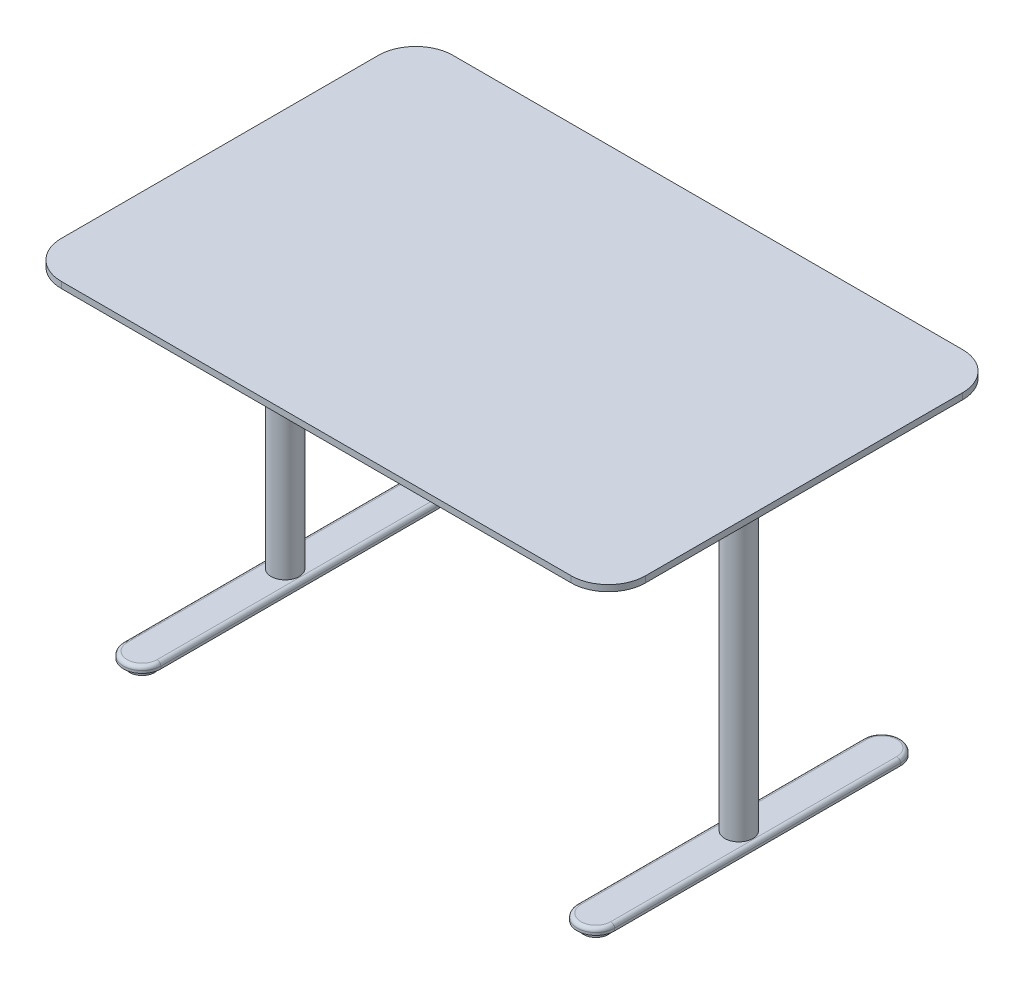
from build123d import *

# Parameters (mm, degrees)
BOSS_EXTRUDE1_DEPTH   = 12.7
SKETCH2_W             = 1054.1
SKETCH2_H             = 457.2
SKETCH2_W_2           = 990.6
SKETCH2_H_2           = 393.7
EXTRUDE_THIN1_DEPTH   = 31.75
SKETCH3_W             = 31.75
SKETCH3_H             = 393.7
BOSS_EXTRUDE3_DEPTH   = 31.75
BOSS_EXTRUDE3_2_DEPTH = 31.75
SKETCH4_W             = 63.5
SKETCH4_H             = 88.9
BOSS_EXTRUDE4_DEPTH   = 12.7
BOSS_EXTRUDE4_2_DEPTH = 12.7
SKETCH5_R             = 28.575
BOSS_EXTRUDE5_DEPTH   = 635
BOSS_EXTRUDE5_2_DEPTH = 635
BOSS_EXTRUDE6_DEPTH   = 12.7
BOSS_EXTRUDE6_2_DEPTH = 12.7
SKETCH7_R             = 25.4
BOSS_EXTRUDE7_DEPTH   = 12.7
BOSS_EXTRUDE7_2_DEPTH = 12.7
BOSS_EXTRUDE7_3_DEPTH = 12.7
BOSS_EXTRUDE7_4_DEPTH = 12.7
FILLET1_R             = 7.62
FILLET2_R             = 7.62


with BuildPart() as part:
    # Sketch1 → Boss-Extrude1 (new body)
    with BuildSketch(Plane(origin=(0, 0, 0), x_dir=(1, 0, 0), z_dir=(0, 1, 0))):
        with BuildLine():
            Line((-520.7, 400.05), (520.7, 400.05))
            ThreePointArc((520.7, 400.05), (574.581536726, 377.731536726), (596.9, 323.85))
            Line((596.9, 323.85), (596.9, -323.85))
            ThreePointArc((596.9, -323.85), (574.581536726, -377.731536726), (520.7, -400.05))
            Line((520.7, -400.05), (-520.7, -400.05))
            ThreePointArc((-520.7, -400.05), (-574.581536726, -377.731536726), (-596.9, -323.85))
            Line((-596.9, -323.85), (-596.9, 323.85))
            ThreePointArc((-596.9, 323.85), (-574.581536726, 377.731536726), (-520.7, 400.05))
        make_face()
    extrude(amount=-BOSS_EXTRUDE1_DEPTH)


with BuildPart() as body_2:
    # Sketch2 → Extrude-Thin1 (new body)
    with BuildSketch(Plane.XZ.offset(12.7)):
        Rectangle(SKETCH2_W, SKETCH2_H)
        Rectangle(SKETCH2_W_2, SKETCH2_H_2, mode=Mode.SUBTRACT)
    extrude(amount=EXTRUDE_THIN1_DEPTH)


with BuildPart() as body_3:
    # Sketch3 → Boss-Extrude3 (new body)
    with BuildSketch(Plane.XZ.offset(44.45)):
        with Locations((-415.925, 0)):
            Rectangle(SKETCH3_W, SKETCH3_H)
    extrude(amount=-BOSS_EXTRUDE3_DEPTH)


with BuildPart() as body_4:
    # Sketch3 → Boss-Extrude3 2 (new body)
    with BuildSketch(Plane.XZ.offset(44.45)):
        with Locations((415.925, 0)):
            Rectangle(SKETCH3_W, SKETCH3_H)
    extrude(amount=-BOSS_EXTRUDE3_2_DEPTH)


with BuildPart() as body_5:
    # Sketch4 → Boss-Extrude4 (new body)
    with BuildSketch(Plane.XZ.offset(44.45)):
        with Locations((-463.55, 0)):
            Rectangle(SKETCH4_W, SKETCH4_H)
    extrude(amount=-BOSS_EXTRUDE4_DEPTH)


with BuildPart() as body_6:
    # Sketch4 → Boss-Extrude4 2 (new body)
    with BuildSketch(Plane.XZ.offset(44.45)):
        with Locations((463.55, 0)):
            Rectangle(SKETCH4_W, SKETCH4_H)
    extrude(amount=-BOSS_EXTRUDE4_2_DEPTH)


with BuildPart() as body_7:
    # Sketch5 → Boss-Extrude5 (new body)
    with BuildSketch(Plane.XZ.offset(44.45)):
        with Locations(Location((-463.55, 0, 0), (0, 0, 270))):  # turned: the seam where the file's is
            Circle(SKETCH5_R)
    extrude(amount=BOSS_EXTRUDE5_DEPTH)


with BuildPart() as body_8:
    # Sketch5 → Boss-Extrude5 2 (new body)
    with BuildSketch(Plane.XZ.offset(44.45)):
        with Locations(Location((463.55, 0, 0), (0, 0, 90))):  # turned: the seam where the file's is
            Circle(SKETCH5_R)
    extrude(amount=BOSS_EXTRUDE5_2_DEPTH)


with BuildPart() as body_9:
    # Sketch6 → Boss-Extrude6 (new body)
    with BuildSketch(Plane.XZ.offset(679.45)):
        with BuildLine():
            Line((-501.65, -292.1), (-501.65, 292.1))
            ThreePointArc((-501.65, 292.1), (-463.55, 330.2), (-425.45, 292.1))
            Line((-425.45, 292.1), (-425.45, -292.1))
            ThreePointArc((-425.45, -292.1), (-463.55, -330.2), (-501.65, -292.1))
        make_face()
    extrude(amount=BOSS_EXTRUDE6_DEPTH)

    # Fillet1
    fillet1_edges = [body_9.edges().sort_by_distance(p)[0] for p in [
        (-501.65, -679.45, 0),
        (-463.55, -679.45, 330.2),
        (-425.45, -679.45, 0),
        (-463.55, -679.45, -330.2),
    ]]
    fillet(fillet1_edges, radius=FILLET1_R)


with BuildPart() as body_10:
    # Sketch6 → Boss-Extrude6 2 (new body)
    with BuildSketch(Plane.XZ.offset(679.45)):
        with BuildLine():
            Line((501.65, -292.1), (501.65, 292.1))
            ThreePointArc((501.65, 292.1), (463.55, 330.2), (425.45, 292.1))
            Line((425.45, 292.1), (425.45, -292.1))
            ThreePointArc((425.45, -292.1), (463.55, -330.2), (501.65, -292.1))
        make_face()
    extrude(amount=BOSS_EXTRUDE6_2_DEPTH)

    # Fillet2
    fillet2_edges = [body_10.edges().sort_by_distance(p)[0] for p in [
        (425.45, -679.45, 0),
        (463.55, -679.45, 330.2),
        (501.65, -679.45, 0),
        (463.55, -679.45, -330.2),
    ]]
    fillet(fillet2_edges, radius=FILLET2_R)


with BuildPart() as body_11:
    # Sketch7 → Boss-Extrude7 (new body)
    with BuildSketch(Plane.XZ.offset(692.15)):
        with Locations(Location((-463.55, 292.1, 0), (0, 0, 270))):  # turned: the seam where the file's is
            Circle(SKETCH7_R)
    extrude(amount=BOSS_EXTRUDE7_DEPTH)


with BuildPart() as body_12:
    # Sketch7 → Boss-Extrude7 2 (new body)
    with BuildSketch(Plane.XZ.offset(692.15)):
        with Locations(Location((463.55, 292.1, 0), (0, 0, 90))):  # turned: the seam where the file's is
            Circle(SKETCH7_R)
    extrude(amount=BOSS_EXTRUDE7_2_DEPTH)


with BuildPart() as body_13:
    # Sketch7 → Boss-Extrude7 3 (new body)
    with BuildSketch(Plane.XZ.offset(692.15)):
        with Locations(Location((463.55, -292.1, 0), (0, 0, 270))):  # turned: the seam where the file's is
            Circle(SKETCH7_R)
    extrude(amount=BOSS_EXTRUDE7_3_DEPTH)


with BuildPart() as body_14:
    # Sketch7 → Boss-Extrude7 4 (new body)
    with BuildSketch(Plane.XZ.offset(692.15)):
        with Locations(Location((-463.55, -292.1, 0), (0, 0, 90))):  # turned: the seam where the file's is
            Circle(SKETCH7_R)
    extrude(amount=BOSS_EXTRUDE7_4_DEPTH)


solid = Compound([part.part, body_2.part, body_3.part, body_4.part, body_5.part, body_6.part, body_7.part, body_8.part, body_9.part, body_10.part, body_11.part, body_12.part, body_13.part, body_14.part])
